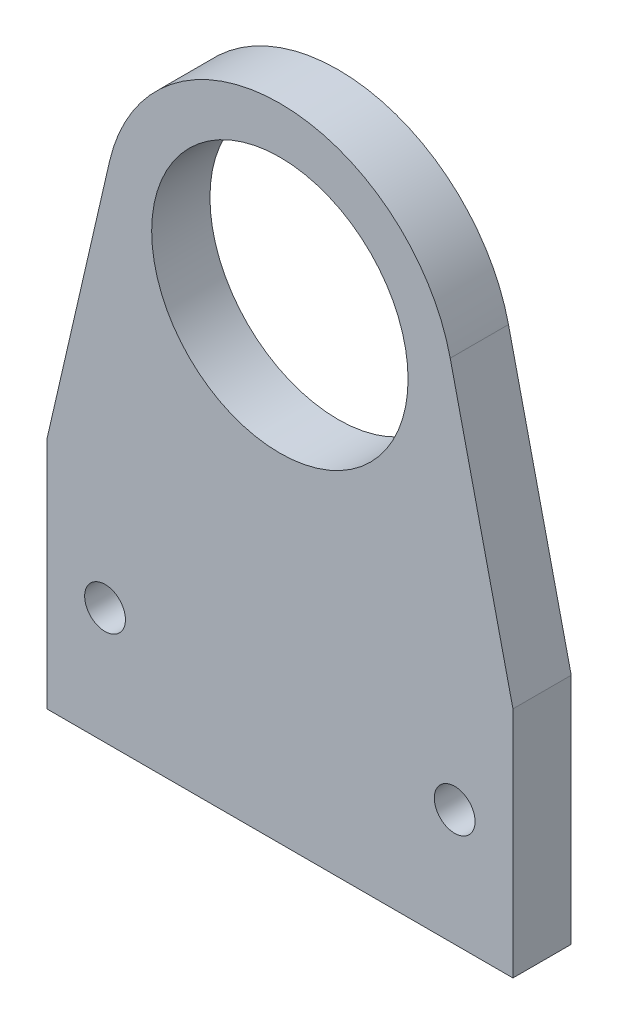
from build123d import *

# Parameters (mm, degrees)
SKETCH1_R           = 11
SKETCH1_R_2         = 1.75
BOSS_EXTRUDE1_DEPTH = 5


with BuildPart() as part:
    # Sketch1 → Boss-Extrude1 (new body)
    with BuildSketch(Plane.XY):
        with BuildLine():
            Line((-14.617184106, 23.367184106), (-20, 0))
            Line((-20, 0), (-20, -20))
            Line((-20, -20), (20, -20))
            Line((20, -20), (20, 0))
            Line((20, 0), (14.617184106, 23.367184106))
            ThreePointArc((14.617184106, 23.367184106), (0, 35), (-14.617184106, 23.367184106))
        make_face()
        with Locations((0, 20)):
            Circle(SKETCH1_R, mode=Mode.SUBTRACT)
        with Locations((-15, -10)):
            Circle(SKETCH1_R_2, mode=Mode.SUBTRACT)
        with Locations((15, -10)):
            Circle(SKETCH1_R_2, mode=Mode.SUBTRACT)
    extrude(amount=BOSS_EXTRUDE1_DEPTH)


solid = part.part
